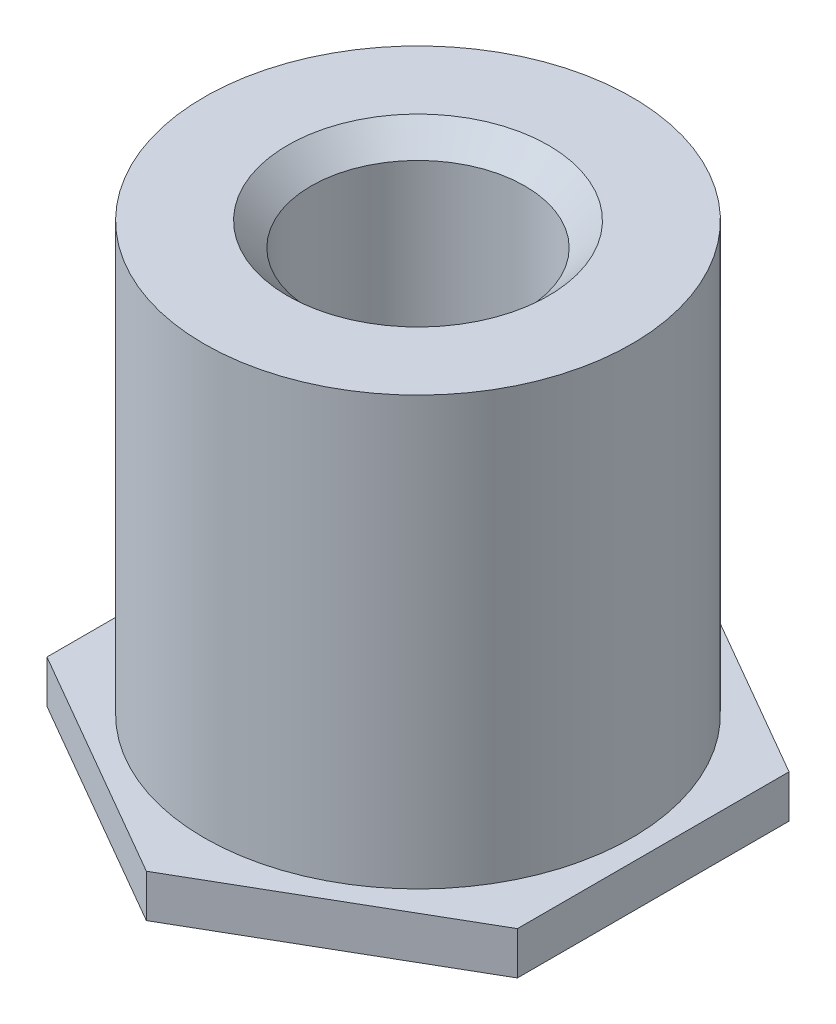
from build123d import *

# Parameters (mm, degrees)
EXTRUDE_1_DEPTH              = 0.5
SKETCH_2_R                   = 2.5
EXTRUDE_2_DEPTH              = 5
HOLE_WIZARD_M3_1_D           = 2.5
HOLE_WIZARD_M3_1_DEPTH       = 4
HOLE_WIZARD_M3_1_CSINK_D     = 3.05
HOLE_WIZARD_M3_1_CSINK_ANGLE = 90
HOLE_WIZARD_M3_1_TIP         = 0.751075774


with BuildPart() as part:
    # 草图1 → 凸台-拉伸1 (new body)
    with BuildSketch(Plane(origin=(0, 0, 0), x_dir=(1, 0, 0), z_dir=(0, 1, 0))):
        Polygon((0, -3.175426481), (2.75, -1.58771324), (2.75, 1.58771324), (0, 3.175426481), (-2.75, 1.58771324), (-2.75, -1.58771324), align=None)
    extrude(amount=EXTRUDE_1_DEPTH)

    # 草图2 → 凸台-拉伸2 (add)
    with BuildSketch(Plane(origin=(0, 0.5, 0), x_dir=(1, 0, 0), z_dir=(0, 1, 0))):
        Circle(SKETCH_2_R)
    extrude(amount=EXTRUDE_2_DEPTH)

    # M3 螺纹孔1
    with Locations(Plane(origin=(0, 5.5, 0), x_dir=(1, 0, 0), z_dir=(0, 1, 0))):
        with Locations((0, 0)):
            CounterSinkHole(HOLE_WIZARD_M3_1_D / 2, HOLE_WIZARD_M3_1_CSINK_D / 2, depth=HOLE_WIZARD_M3_1_DEPTH, counter_sink_angle=HOLE_WIZARD_M3_1_CSINK_ANGLE)
            with Locations((0, 0, -(HOLE_WIZARD_M3_1_DEPTH + HOLE_WIZARD_M3_1_TIP / 2))):  # 118° drill point
                Cone(0, HOLE_WIZARD_M3_1_D / 2, HOLE_WIZARD_M3_1_TIP, mode=Mode.SUBTRACT)


solid = part.part
